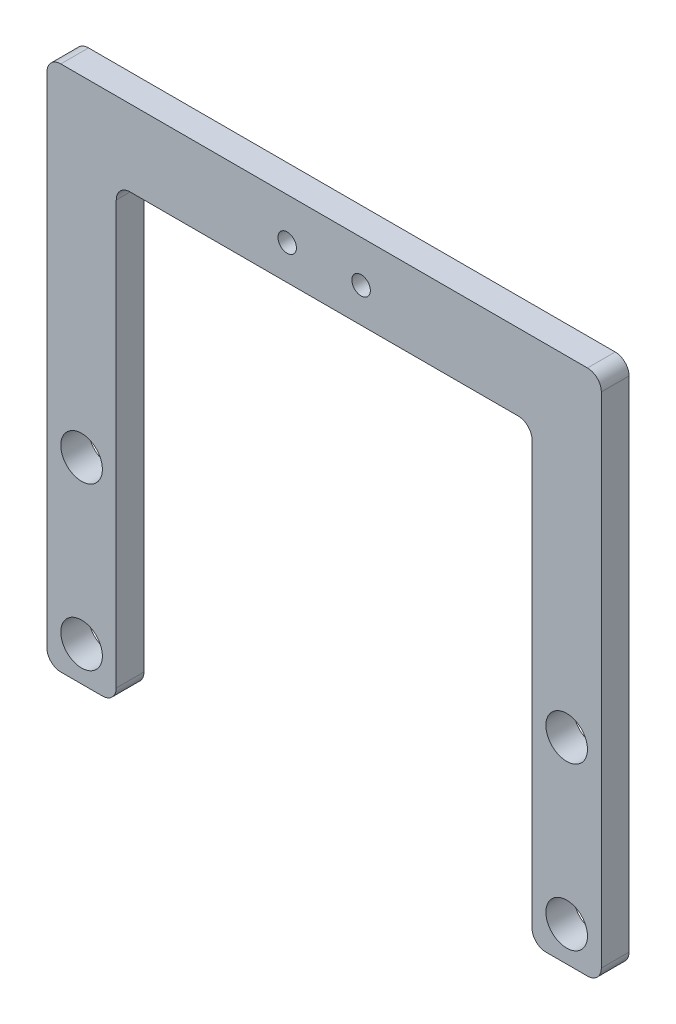
from build123d import *

# Parameters (mm, degrees)
SKETCH1_R           = 2
SKETCH1_R_2         = 4.5
BOSS_EXTRUDE1_DEPTH = 6


with BuildPart() as part:
    # Sketch1 → Boss-Extrude1 (new body)
    with BuildSketch(Plane.XY):
        with BuildLine():
            Line((-45, -39.5), (-45, 52))
            ThreePointArc((-45, 52), (-44.121320344, 54.121320344), (-42, 55))
            Line((-42, 55), (42, 55))
            ThreePointArc((42, 55), (44.121320344, 54.121320344), (45, 52))
            Line((45, 52), (45, -39.5))
            ThreePointArc((45, -39.5), (45.878679656, -41.621320344), (48, -42.5))
            Line((48, -42.5), (57, -42.5))
            ThreePointArc((57, -42.5), (59.121320344, -41.621320344), (60, -39.5))
            Line((60, -39.5), (60, 68.5))
            ThreePointArc((60, 68.5), (59.121320344, 70.621320344), (57, 71.5))
            Line((57, 71.5), (-57, 71.5))
            ThreePointArc((-57, 71.5), (-59.121320344, 70.621320344), (-60, 68.5))
            Line((-60, 68.5), (-60, -39.5))
            ThreePointArc((-60, -39.5), (-59.121320344, -41.621320344), (-57, -42.5))
            Line((-57, -42.5), (-48, -42.5))
            ThreePointArc((-48, -42.5), (-45.878679656, -41.621320344), (-45, -39.5))
        make_face()
        with Locations((8, 62.5)):
            Circle(SKETCH1_R, mode=Mode.SUBTRACT)
        with Locations((-8, 62.5)):
            Circle(SKETCH1_R, mode=Mode.SUBTRACT)
        with Locations((-52.5, -35)):
            Circle(SKETCH1_R_2, mode=Mode.SUBTRACT)
        with Locations((52.5, -35)):
            Circle(SKETCH1_R_2, mode=Mode.SUBTRACT)
        with Locations((-52.5, 0)):
            Circle(SKETCH1_R_2, mode=Mode.SUBTRACT)
        with Locations((52.5, 0)):
            Circle(SKETCH1_R_2, mode=Mode.SUBTRACT)
    extrude(amount=BOSS_EXTRUDE1_DEPTH)


solid = part.part
